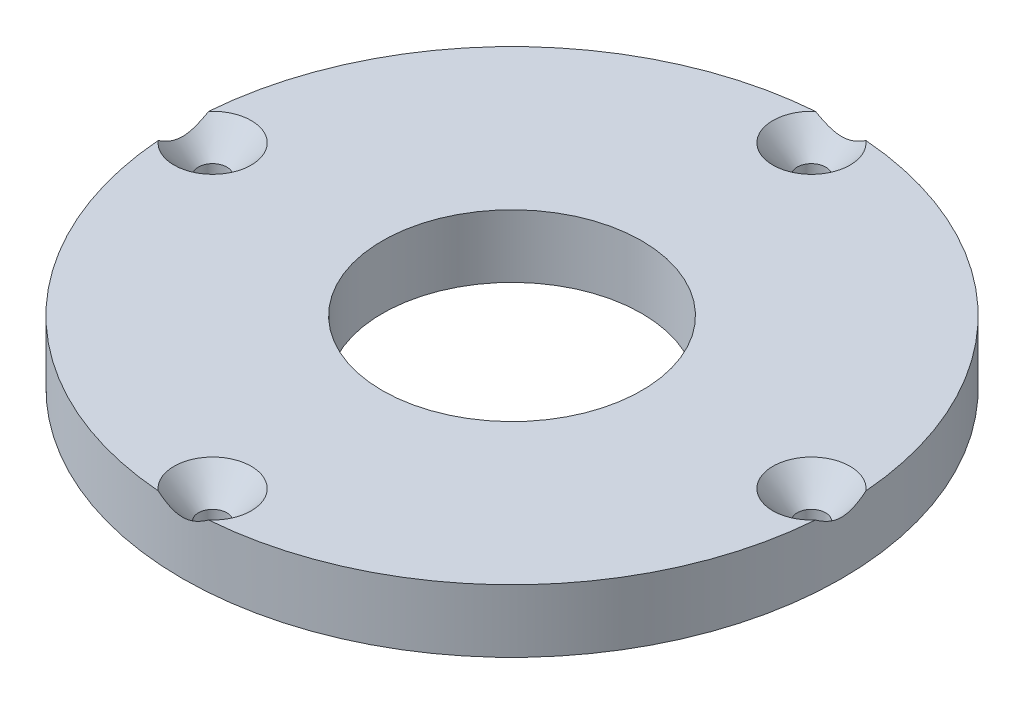
from build123d import *

# Parameters (mm, degrees)
SKETCH1_R                 = 33.274
BOSS_EXTRUDE1_DEPTH       = 6.35
PLATEMTGSCREW_D           = 2.8702
PLATEMTGSCREW_DEPTH       = 10.1854
PLATEMTGSCREW_CSINK_D     = 7.7978
PLATEMTGSCREW_CSINK_ANGLE = 82
PLATEMTGSCREW_TIP         = 0.862295074
SHAFTBORE_D               = 26.19375
SHAFTBORE_DEPTH           = 6.35
SHAFTBORE_TIP             = 7.86939642


with BuildPart() as part:
    # Sketch1 → Boss-Extrude1 (new body)
    with BuildSketch(Plane(origin=(0, 0, 0), x_dir=(1, 0, 0), z_dir=(0, 1, 0))):
        Circle(SKETCH1_R)
    extrude(amount=BOSS_EXTRUDE1_DEPTH)

    # PlateMtgScrew
    with Locations(Plane(origin=(0, 6.35, 0), x_dir=(1, 0, 0), z_dir=(0, 1, 0))):
        with Locations((0, 30.226), (-30.226, 0), (0, -30.226), (30.226, 0)):
            CounterSinkHole(PLATEMTGSCREW_D / 2, PLATEMTGSCREW_CSINK_D / 2, depth=PLATEMTGSCREW_DEPTH, counter_sink_angle=PLATEMTGSCREW_CSINK_ANGLE)
            with Locations((0, 0, -(PLATEMTGSCREW_DEPTH + PLATEMTGSCREW_TIP / 2))):  # 118° drill point
                Cone(0, PLATEMTGSCREW_D / 2, PLATEMTGSCREW_TIP, mode=Mode.SUBTRACT)

    # ShaftBore
    with Locations(Plane(origin=(0, 6.35, 0), x_dir=(1, 0, 0), z_dir=(0, 1, 0))):
        with Locations((0, 0)):
            Hole(SHAFTBORE_D / 2, depth=SHAFTBORE_DEPTH)
            with Locations((0, 0, -(SHAFTBORE_DEPTH + SHAFTBORE_TIP / 2))):  # 118° drill point
                Cone(0, SHAFTBORE_D / 2, SHAFTBORE_TIP, mode=Mode.SUBTRACT)


solid = part.part
